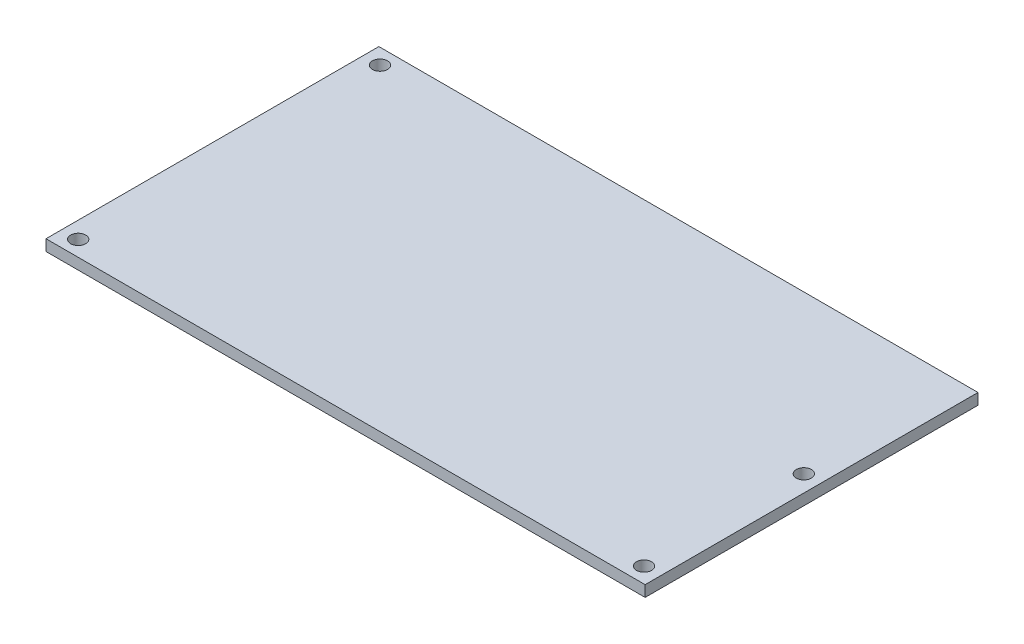
from build123d import *

# Parameters (mm, degrees)
SKETCH1_W           = 135
SKETCH1_H           = 75
BOSS_EXTRUDE1_DEPTH = 2.5
CUT_EXTRUDE1_REACH  = 4.5
SKETCH2_R           = 1.7


with BuildPart() as part:
    # Sketch1 → Boss-Extrude1 (new body)
    with BuildSketch(Plane(origin=(0, 0, 0), x_dir=(1, 0, 0), z_dir=(0, 1, 0))):
        Rectangle(SKETCH1_W, SKETCH1_H)
    extrude(amount=BOSS_EXTRUDE1_DEPTH)

    # Sketch2 → Cut-Extrude1 (cut, up to next)
    with BuildSketch(Plane(origin=(0, 0, 0), x_dir=(1, 0, 0), z_dir=(0, 1, 0)), mode=Mode.PRIVATE) as cut_extrude1_sk1:
        with Locations((63.75, -34)):
            Circle(SKETCH2_R)
    cut_extrude1_tool1 = extrude(cut_extrude1_sk1.sketch, amount=CUT_EXTRUDE1_REACH, mode=Mode.PRIVATE) & part.part
    add(cut_extrude1_tool1.solids().sort_by_distance((63.75, 0, 34))[0], mode=Mode.SUBTRACT)
    # Sketch2 → Cut-Extrude1 (cut, up to next)
    with BuildSketch(Plane(origin=(0, 0, 0), x_dir=(1, 0, 0), z_dir=(0, 1, 0)), mode=Mode.PRIVATE) as cut_extrude1_sk2:
        with Locations((63.75, 2)):
            Circle(SKETCH2_R)
    cut_extrude1_tool2 = extrude(cut_extrude1_sk2.sketch, amount=CUT_EXTRUDE1_REACH, mode=Mode.PRIVATE) & part.part
    add(cut_extrude1_tool2.solids().sort_by_distance((63.75, 0, -2))[0], mode=Mode.SUBTRACT)
    # Sketch2 → Cut-Extrude1 (cut, up to next)
    with BuildSketch(Plane(origin=(0, 0, 0), x_dir=(1, 0, 0), z_dir=(0, 1, 0)), mode=Mode.PRIVATE) as cut_extrude1_sk3:
        with Locations((-63.75, -34)):
            Circle(SKETCH2_R)
    cut_extrude1_tool3 = extrude(cut_extrude1_sk3.sketch, amount=CUT_EXTRUDE1_REACH, mode=Mode.PRIVATE) & part.part
    add(cut_extrude1_tool3.solids().sort_by_distance((-63.75, 0, 34))[0], mode=Mode.SUBTRACT)
    # Sketch2 → Cut-Extrude1 (cut, up to next)
    with BuildSketch(Plane(origin=(0, 0, 0), x_dir=(1, 0, 0), z_dir=(0, 1, 0)), mode=Mode.PRIVATE) as cut_extrude1_sk4:
        with Locations((-63.75, 34)):
            Circle(SKETCH2_R)
    cut_extrude1_tool4 = extrude(cut_extrude1_sk4.sketch, amount=CUT_EXTRUDE1_REACH, mode=Mode.PRIVATE) & part.part
    add(cut_extrude1_tool4.solids().sort_by_distance((-63.75, 0, -34))[0], mode=Mode.SUBTRACT)


solid = part.part
